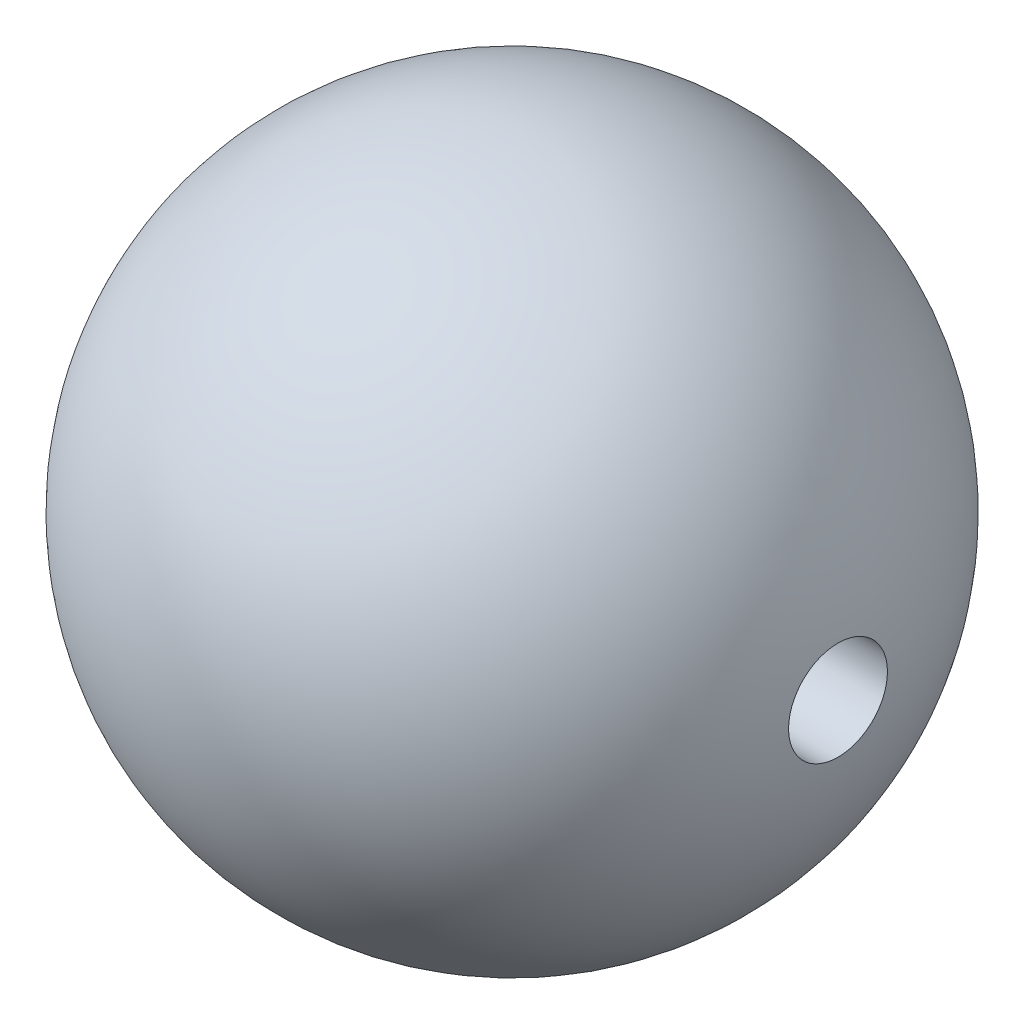
from build123d import *

# Parameters (mm, degrees)
SKETCH3_R          = 1.5
CUT_EXTRUDE1_DEPTH = 10


with BuildPart() as part:
    # Sketch2 → Revolve1 (revolve)
    with BuildSketch(Plane(origin=(0, 0, 0), x_dir=(1, 0, 0), z_dir=(0, 1, 0))):
        with BuildLine():
            Line((0, 0), (10, 0))
            ThreePointArc((10, 0), (7.071067812, 7.071067812), (0, 10))
            Line((0, 10), (0, 0))
        make_face()
    revolve1 = revolve(axis=Axis((0, 0, 0), (1, 0, 0)))

    # Mirror1: Revolve1 across plane
    add(revolve1.mirror(Plane(origin=(0, 0, 0), x_dir=(0, 0, 1), z_dir=(1, 0, 0))))

    # Sketch3 → Cut-Extrude1 (cut)
    with BuildSketch(Plane(origin=(0, 0, 0), x_dir=(0, 0, -1), z_dir=(1, 0, 0))):
        Circle(SKETCH3_R)
    extrude(amount=CUT_EXTRUDE1_DEPTH, mode=Mode.SUBTRACT)


solid = part.part
